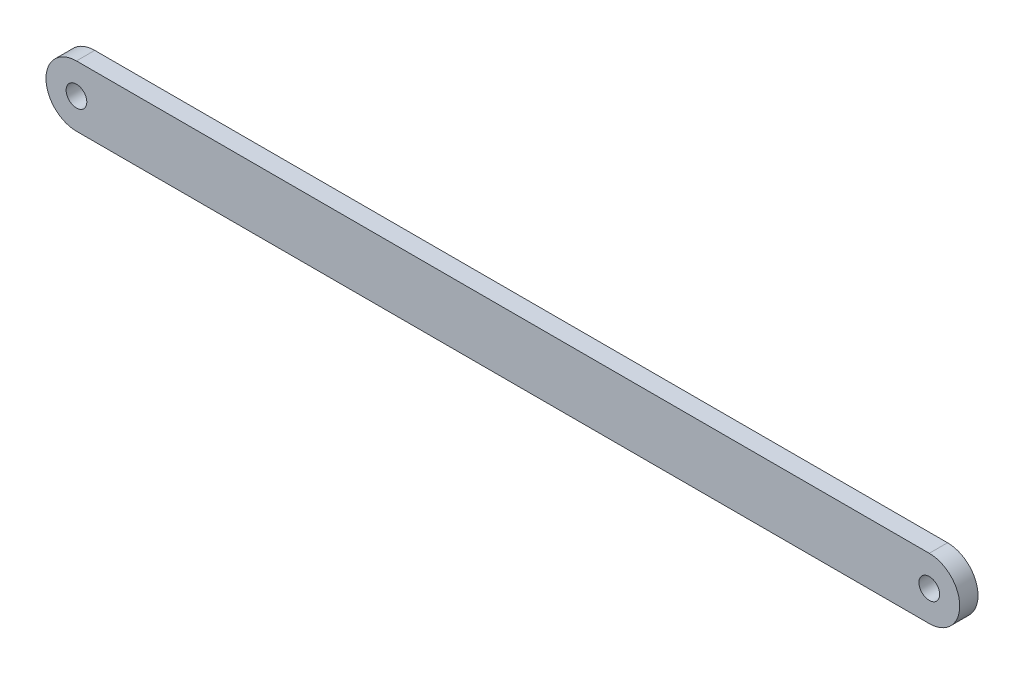
from build123d import *

# Parameters (mm, degrees)
AUFSATZ_LINEAR_AUSTRAGEN1_DEPTH = 1.5
DURCHGANGSLOCH_F_R_M31_D        = 3.4


with BuildPart() as part:
    # Skizze1 → Aufsatz-Linear austragen1 (new body, symmetric)
    with BuildSketch(Plane.XY):
        with BuildLine():
            Line((-70, 5), (70, 5))
            ThreePointArc((70, 5), (75, 0), (70, -5))
            Line((70, -5), (-70, -5))
            ThreePointArc((-70, -5), (-75, 0), (-70, 5))
        make_face()
    extrude(amount=AUFSATZ_LINEAR_AUSTRAGEN1_DEPTH, both=True)

    # Durchgangsloch für M31 (through all)
    with Locations(Plane.XY.offset(1.5)):
        with Locations((-70, 0), (70, 0)):
            Hole(DURCHGANGSLOCH_F_R_M31_D / 2)


solid = part.part
